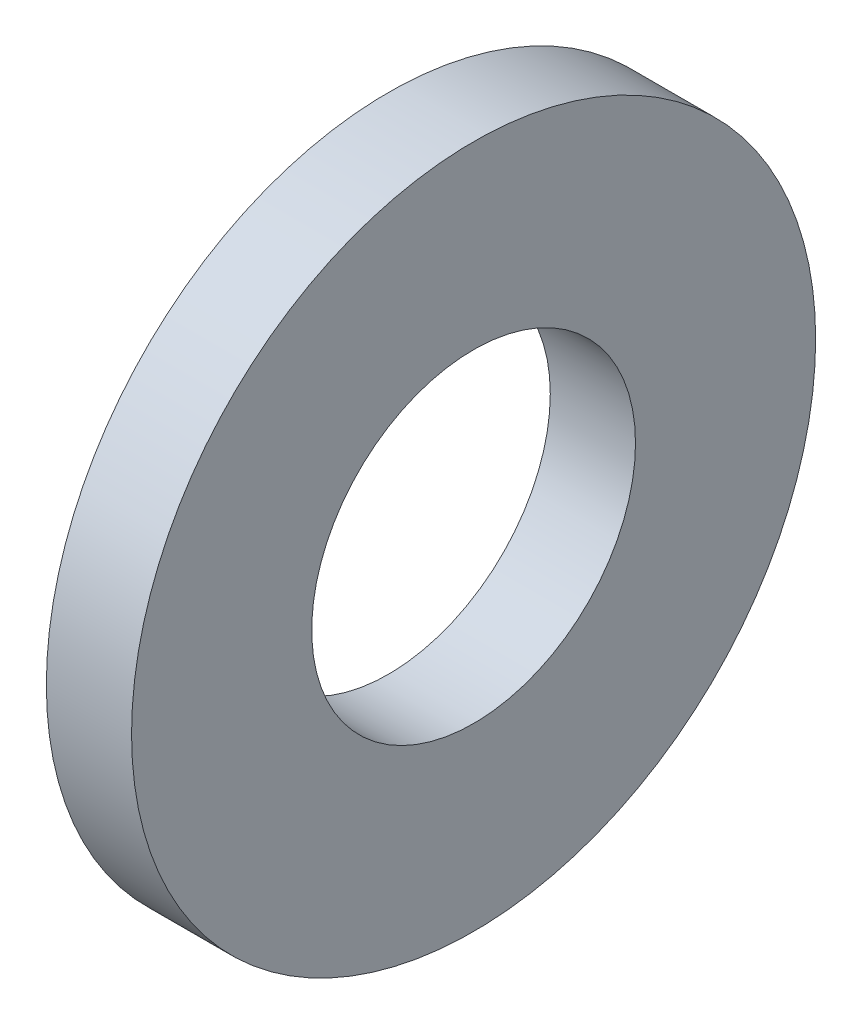
from build123d import *

# Parameters (mm, degrees)
SKETCH1_R           = 7.1374
SKETCH1_R_2         = 3.3782
BOSS_EXTRUDE1_DEPTH = 1.778


with BuildPart() as part:
    # Sketch1 → Boss-Extrude1 (new body)
    with BuildSketch(Plane(origin=(0, 0, 0), x_dir=(0, 0, -1), z_dir=(1, 0, 0))):
        Circle(SKETCH1_R)
        Circle(SKETCH1_R_2, mode=Mode.SUBTRACT)
    extrude(amount=BOSS_EXTRUDE1_DEPTH)


solid = part.part
